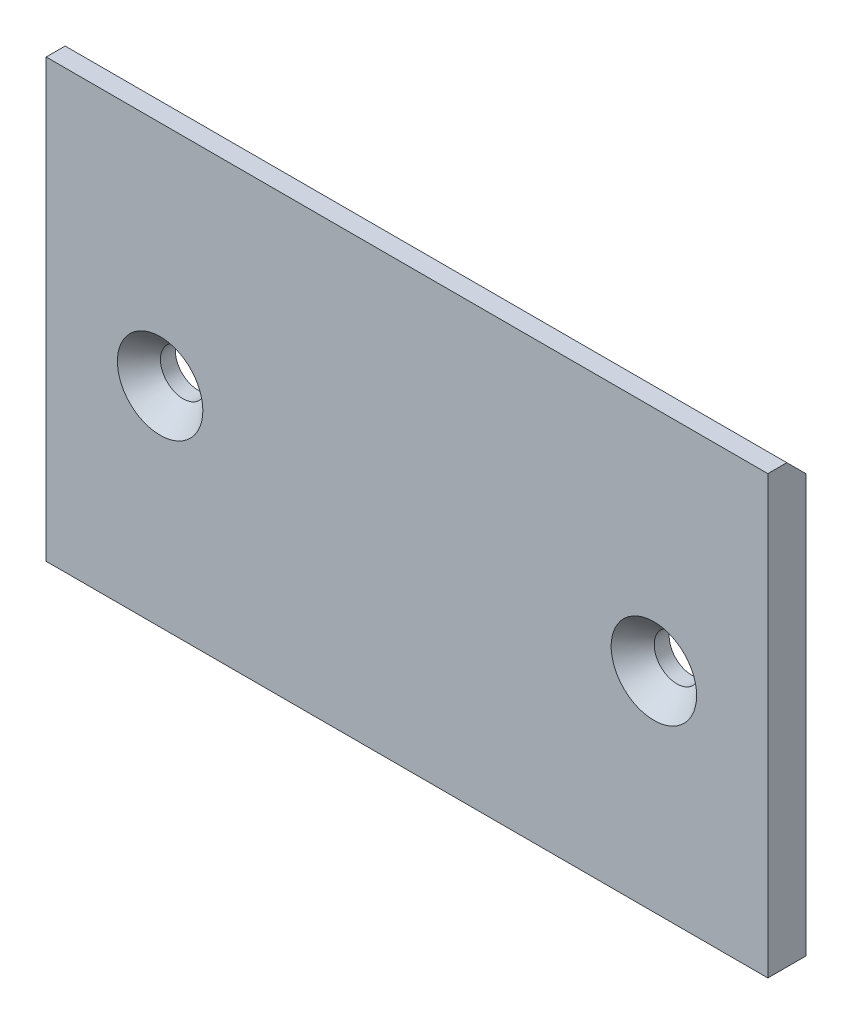
from build123d import *

# Parameters (mm, degrees)
SKETCH1_W                       = 60.325
SKETCH1_H                       = 36.5125
EXTRUDE1_DEPTH                  = 1.5875
CHAMFER1_SIZE                   = 1.5875
F_6_CLEARANCE_HOLE1_D           = 3.7973
F_6_CLEARANCE_HOLE1_DEPTH       = 25.4
F_6_CLEARANCE_HOLE1_CSINK_D     = 7.14375
F_6_CLEARANCE_HOLE1_CSINK_ANGLE = 82
F_6_CLEARANCE_HOLE1_TIP         = 1.140824014


with BuildPart() as part:
    # Sketch1 → Extrude1 (new body, symmetric)
    with BuildSketch(Plane.XY):
        Rectangle(SKETCH1_W, SKETCH1_H)
    extrude(amount=EXTRUDE1_DEPTH, both=True)

    # Chamfer1
    chamfer1_edges = [part.edges().sort_by_distance(p)[0] for p in [
        (0, 18.25625, -1.5875),
    ]]
    chamfer(chamfer1_edges, length=CHAMFER1_SIZE)

    # #6 Clearance Hole1
    with Locations(Plane(origin=(-20.6375, -0.79375, 1.5875), x_dir=(1, 0, 0), z_dir=(0, 0, 1))):
        with Locations((0, 0), (41.275, 0)):
            CounterSinkHole(F_6_CLEARANCE_HOLE1_D / 2, F_6_CLEARANCE_HOLE1_CSINK_D / 2, depth=F_6_CLEARANCE_HOLE1_DEPTH, counter_sink_angle=F_6_CLEARANCE_HOLE1_CSINK_ANGLE)
            with Locations((0, 0, -(F_6_CLEARANCE_HOLE1_DEPTH + F_6_CLEARANCE_HOLE1_TIP / 2))):  # 118° drill point
                Cone(0, F_6_CLEARANCE_HOLE1_D / 2, F_6_CLEARANCE_HOLE1_TIP, mode=Mode.SUBTRACT)


solid = part.part
